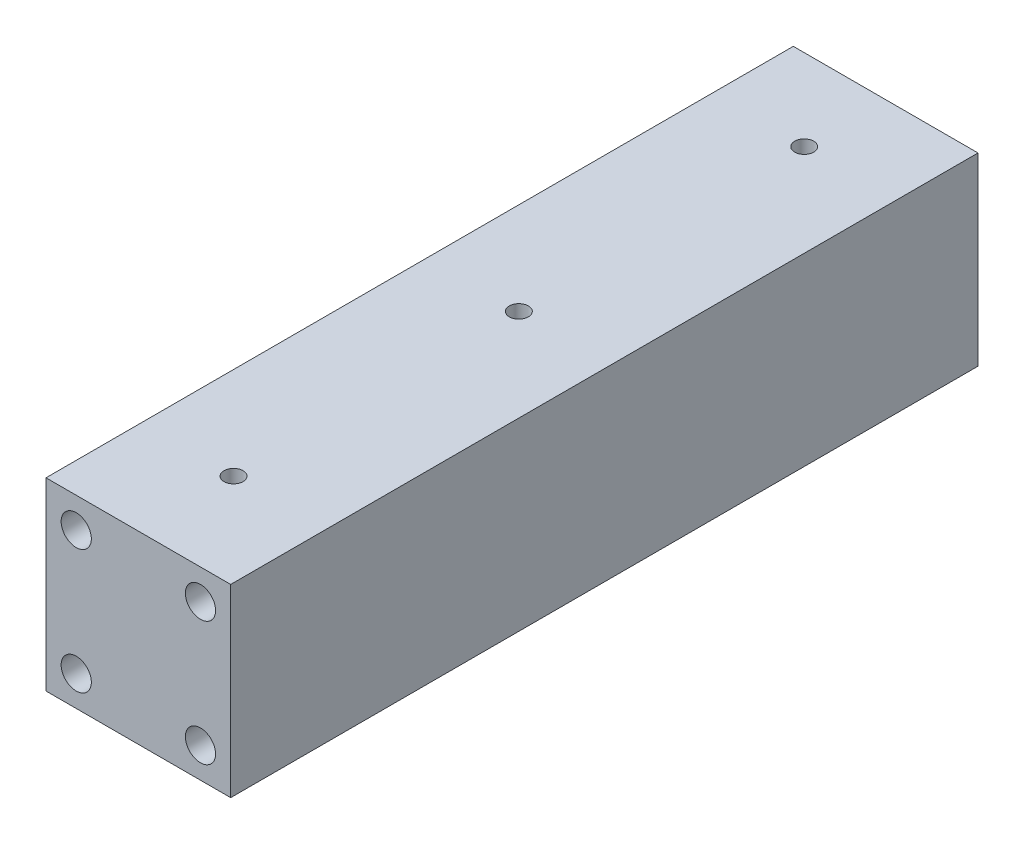
from build123d import *

# Parameters (mm, degrees)
SKETCH1_W           = 12.90052
SKETCH1_H           = 156.99994
SKETCH1_W_2         = 13
SKETCH1_R           = 2
BOSS_EXTRUDE1_DEPTH = 38.80104
CUT_EXTRUDE1_START  = 38.80104
SKETCH1_3_R         = 2
CUT_EXTRUDE1_DEPTH  = 6.35
SKETCH2_R           = 3.175
CUT_EXTRUDE2_DEPTH  = 12.7
CUT_EXTRUDE3_START  = -156.99994
SKETCH2_3_R         = 3.175
CUT_EXTRUDE3_DEPTH  = 12.7


with BuildPart() as part:
    # Sketch1 → Boss-Extrude1 (new body)
    with BuildSketch(Plane(origin=(0, 0, 0), x_dir=(1, 0, 0), z_dir=(0, 1, 0))):
        with Locations((-6.45026, 78.49997)):
            Rectangle(SKETCH1_W, SKETCH1_H)
        with Locations((6.5, 78.49997)):
            Rectangle(SKETCH1_W_2, SKETCH1_H)
        with Locations((6.5, 20)):
            Circle(SKETCH1_R, mode=Mode.SUBTRACT)
        with Locations((6.5, 79.944)):
            Circle(SKETCH1_R, mode=Mode.SUBTRACT)
        with Locations((6.5, 139.888)):
            Circle(SKETCH1_R, mode=Mode.SUBTRACT)
        with Locations((19.45026, 78.49997)):
            Rectangle(SKETCH1_W, SKETCH1_H)
        with Locations((6.5, 20)):
            Circle(SKETCH1_R)
        with Locations((6.5, 139.888)):
            Circle(SKETCH1_R)
        with Locations((6.5, 79.944)):
            Circle(SKETCH1_R)
    extrude(amount=BOSS_EXTRUDE1_DEPTH)

    # Sketch1_3 → Cut-Extrude1 (cut)
    with BuildSketch(Plane(origin=(0, 0, 0), x_dir=(1, 0, 0), z_dir=(0, 1, 0)).offset(CUT_EXTRUDE1_START)):
        with Locations((6.5, 20)):
            Circle(SKETCH1_3_R)
        with Locations((6.5, 79.944)):
            Circle(SKETCH1_3_R)
        with Locations((6.5, 139.888)):
            Circle(SKETCH1_3_R)
    extrude(amount=-CUT_EXTRUDE1_DEPTH, mode=Mode.SUBTRACT)

    # Sketch2 → Cut-Extrude2 (cut)
    with BuildSketch(Plane.XY):
        with Locations((-6.55052, 32.45104)):
            Circle(SKETCH2_R)
        with Locations((19.55052, 32.45104)):
            Circle(SKETCH2_R)
        with Locations((19.55052, 6.35)):
            Circle(SKETCH2_R)
        with Locations((-6.55052, 6.35)):
            Circle(SKETCH2_R)
    extrude(amount=-CUT_EXTRUDE2_DEPTH, mode=Mode.SUBTRACT)

    # Sketch2_3 → Cut-Extrude3 (cut)
    with BuildSketch(Plane.XY.offset(CUT_EXTRUDE3_START)):
        with Locations((-6.55052, 32.45104)):
            Circle(SKETCH2_3_R)
        with Locations((19.55052, 32.45104)):
            Circle(SKETCH2_3_R)
        with Locations((19.55052, 6.35)):
            Circle(SKETCH2_3_R)
        with Locations((-6.55052, 6.35)):
            Circle(SKETCH2_3_R)
    extrude(amount=CUT_EXTRUDE3_DEPTH, mode=Mode.SUBTRACT)


solid = part.part
